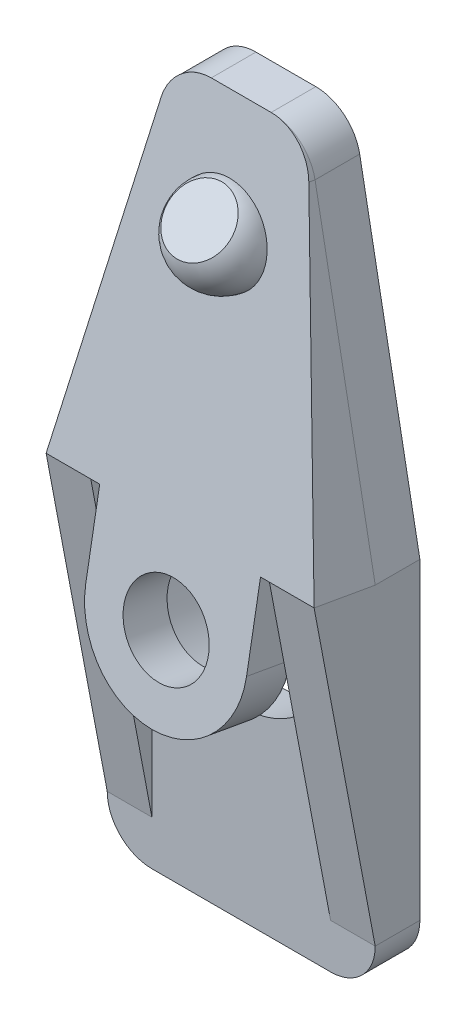
from build123d import *
from build123d.topology import SkipClean

# Parameters (mm, degrees)
BOSS_EXTRUDE1_DEPTH     = 2
SKETCH2_R               = 1.9
BOSS_EXTRUDE2_DEPTH     = 2
CUT_EXTRUDE1_REACH      = 24.481
SKETCH4_R               = 4
BOSS_EXTRUDE3_REACH     = 24.481
BOSS_EXTRUDE4_DEPTH     = 2
BOSS_EXTRUDE5_DEPTH     = 2
CUT_EXTRUDE2_DEPTH      = 0.3
REVOLVE1_ANGLE          = 180
CUT_EXTRUDE3_DEPTH      = 24.576202563
CUT_EXTRUDE3_DEPTH_BACK = 24.576202563


with BuildPart() as part:
    # Sketch1 → Boss-Extrude1 (new body)
    with BuildSketch(Plane.XY):
        with BuildLine():
            Line((-4, -10), (4, -10))
            ThreePointArc((4, -10), (5.414213562, -9.414213562), (6, -8))
            Line((6, -8), (6, 6))
            Line((6, 6), (3.305891799, 20.36857707))
            ThreePointArc((3.305891799, 20.36857707), (2.6174191, 21.539018216), (1.340147425, 22))
            Line((1.340147425, 22), (-1.340147425, 22))
            ThreePointArc((-1.340147425, 22), (-2.6174191, 21.539018216), (-3.305891799, 20.36857707))
            Line((-3.305891799, 20.36857707), (-6, 6))
            Line((-6, 6), (-6, -8))
            ThreePointArc((-6, -8), (-5.414213562, -9.414213562), (-4, -10))
        make_face()
    extrude(amount=BOSS_EXTRUDE1_DEPTH)

    # Sketch2 → Boss-Extrude2 (add)
    with BuildSketch(Plane(origin=(0, 1.005401315, 5.701914197), x_dir=(-1, 0, 0), z_dir=(0, 0.1736481776669307, 0.984807753012208))):
        with BuildLine():
            Line((-3.6, -1.961550163), (-3.6, -5.561550163))
            Line((-3.6, -5.561550163), (-6, -5.561550163))
            Line((-6, -5.561550163), (-3.305891799, -19.711836261))
            add(Edge.make_bspline(
                [(-3.305891799, -19.711836261), (-3, -21.318474211), (-1.340147425, -21.318474211)],
                knots=[3.326940604, 3.326940604, 3.326940604, 4.71238898, 4.71238898, 4.71238898], degree=2, weights=[1, 0.769509108, 1]))
            Line((-1.340147425, -21.318474211), (1.340147425, -21.318474211))
            add(Edge.make_bspline(
                [(1.340147425, -21.318474211), (3, -21.318474211), (3.305891799, -19.711836261)],
                knots=[4.71238898, 4.71238898, 4.71238898, 6.097837357, 6.097837357, 6.097837357], degree=2, weights=[1, 0.769509108, 1]))
            Line((3.305891799, -19.711836261), (6, -5.561550163))
            Line((6, -5.561550163), (3.6, -5.561550163))
            Line((3.6, -5.561550163), (3.6, -1.961550163))
            ThreePointArc((3.6, -1.961550163), (0, 1.638449837), (-3.6, -1.961550163))
        make_face()
        with Locations(Location((0, -1.961550163, 0), (0, 0, 90))):
            Circle(SKETCH2_R, mode=Mode.SUBTRACT)
    extrude(amount=-BOSS_EXTRUDE2_DEPTH)

    # Cut-Extrude1: up to this plane
    cut_extrude1_end = Plane(origin=(1.340147425, 20, 0), z_dir=(0, 0, 1))
    # Sketch4 → Cut-Extrude1 (cut, up to the surface)
    with BuildSketch(Plane(origin=(0, 0.658104959, 3.732298691), x_dir=(-1, 0, 0), z_dir=(0, -0.1736481776669307, -0.9848077530122081)), mode=Mode.PRIVATE) as cut_extrude1_sk1:
        with Locations(Location((0, 1.961550163, 0), (0, 0, 90))):
            Circle(SKETCH4_R)
    cut_extrude1_tool1 = split(extrude(cut_extrude1_sk1.sketch, amount=CUT_EXTRUDE1_REACH, mode=Mode.PRIVATE), bisect_by=cut_extrude1_end, keep=Keep.BOTH, mode=Mode.PRIVATE)
    add(cut_extrude1_tool1.solids().sort_by_distance((0, 2.589855, 3.391679))[0], mode=Mode.SUBTRACT)

    # Sketch5 → Boss-Extrude3 (add, up to next)
    with BuildSketch(Plane(origin=(0, 0.658104959, 3.732298691), x_dir=(-1, 0, 0), z_dir=(0, -0.1736481776669307, -0.9848077530122081)), mode=Mode.PRIVATE) as boss_extrude3_sk1:
        with BuildLine():
            Line((-6, 5.561550163), (-4, 5.561550163))
            ThreePointArc((-4, 5.561550163), (0, 7.342999782), (4, 5.561550163))
            Line((4, 5.561550163), (6, 5.561550163))
            Line((6, 5.561550163), (5.159538931, 9.975910572))
            Line((5.159538931, 9.975910572), (-5.159538931, 9.975910572))
            Line((-5.159538931, 9.975910572), (-6, 5.561550163))
        make_face()
    boss_extrude3_tool1 = extrude(boss_extrude3_sk1.sketch, amount=BOSS_EXTRUDE3_REACH, mode=Mode.PRIVATE) - part.part
    add(boss_extrude3_tool1.solids().sort_by_distance((0, 8.606511, 2.33078))[0])

    # Sketch6 → Boss-Extrude4 (add)
    with BuildSketch(Plane(origin=(6, 0, 0), x_dir=(0, 0, -1), z_dir=(1, 0, 0))):
        Polygon((-4.736161147, 6.482459034), (-2, 6), (-2, -8), align=None)
    extrude(amount=-BOSS_EXTRUDE4_DEPTH)

    # Sketch7 → Boss-Extrude5 (add)
    with BuildSketch(Plane.ZY.offset(6)):
        Polygon((2, 6), (4.736161147, 6.482459034), (2, -8), align=None)
    extrude(amount=-BOSS_EXTRUDE5_DEPTH)

    # Sketch8 → Cut-Extrude2 (cut)
    with BuildSketch(Plane(origin=(0, 0, 0), x_dir=(-1, 0, 0), z_dir=(0, 0, -1))):
        with BuildLine():
            Line((-4, -3.5), (4, -3.5))
            ThreePointArc((4, -3.5), (4.75, -4.25), (4, -5))
            Line((4, -5), (-4, -5))
            ThreePointArc((-4, -5), (-4.75, -4.25), (-4, -3.5))
        make_face()
        with BuildLine():
            Line((-4, -6.5), (4, -6.5))
            ThreePointArc((4, -6.5), (4.75, -7.25), (4, -8))
            Line((4, -8), (-4, -8))
            ThreePointArc((-4, -8), (-4.75, -7.25), (-4, -6.5))
        make_face()
    extrude(amount=-CUT_EXTRUDE2_DEPTH, mode=Mode.SUBTRACT)

    # Sketch9 → Revolve1 (revolve)
    with BuildSketch(Plane(origin=(0, 1.005401315, 5.701914197), x_dir=(1, 0, 0), z_dir=(0, 0.1736481776669307, 0.9848077530122081))):
        with BuildLine():
            Line((-2, 16.318474211), (2, 16.318474211))
            ThreePointArc((2, 16.318474211), (0, 14.318474211), (-2, 16.318474211))
        make_face()
    revolve(axis=Axis((0, 17.075961235, 2.868240888), (-1, 0, 0)), revolution_arc=REVOLVE1_ANGLE)

    # Sketch11 → Cut-Extrude3 (cut, two sides)
    with SkipClean():  # the faces are left unmerged after this step: merging them gives an invalid solid
        with BuildSketch(Plane(origin=(0, 0, 0), x_dir=(0, 0, -1), z_dir=(1, 0, 0))) as cut_extrude3_sk:
            Polygon((-4.868240888, 17.075961235), (-2.868240888, 19.075961235), (-5.75514434, 19.075961235), align=None)
        extrude(amount=CUT_EXTRUDE3_DEPTH, mode=Mode.SUBTRACT)
        extrude(cut_extrude3_sk.sketch, amount=-CUT_EXTRUDE3_DEPTH_BACK, mode=Mode.SUBTRACT)


solid = part.part
